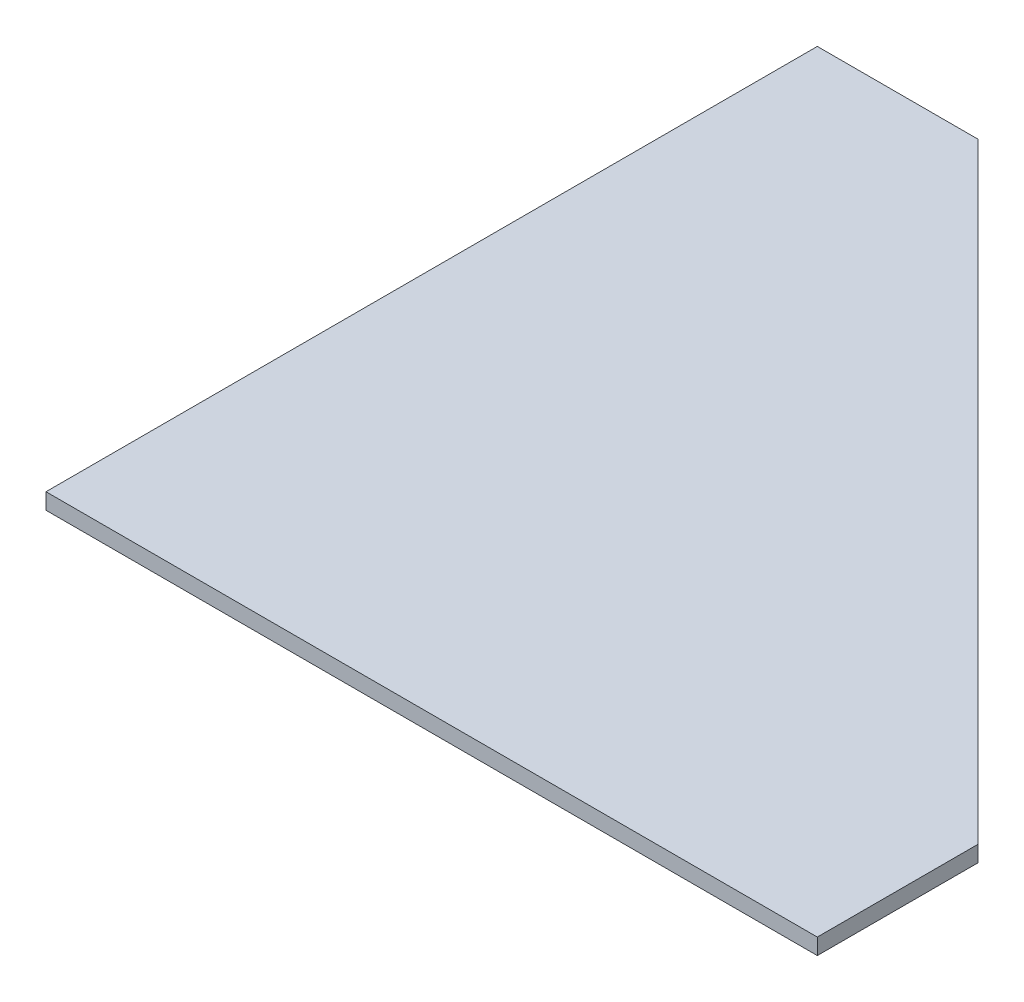
from build123d import *

# Parameters (mm, degrees)
BOSS_EXTRUDE1_DEPTH = 12.7


with BuildPart() as part:
    # Sketch1 → Boss-Extrude1 (new body)
    with BuildSketch(Plane(origin=(0, 0, 0), x_dir=(1, 0, 0), z_dir=(0, 1, 0))):
        Polygon((0, 0), (609.6, 0), (609.6, 127), (127, 609.6), (0, 609.6), align=None)
    extrude(amount=BOSS_EXTRUDE1_DEPTH)


solid = part.part
